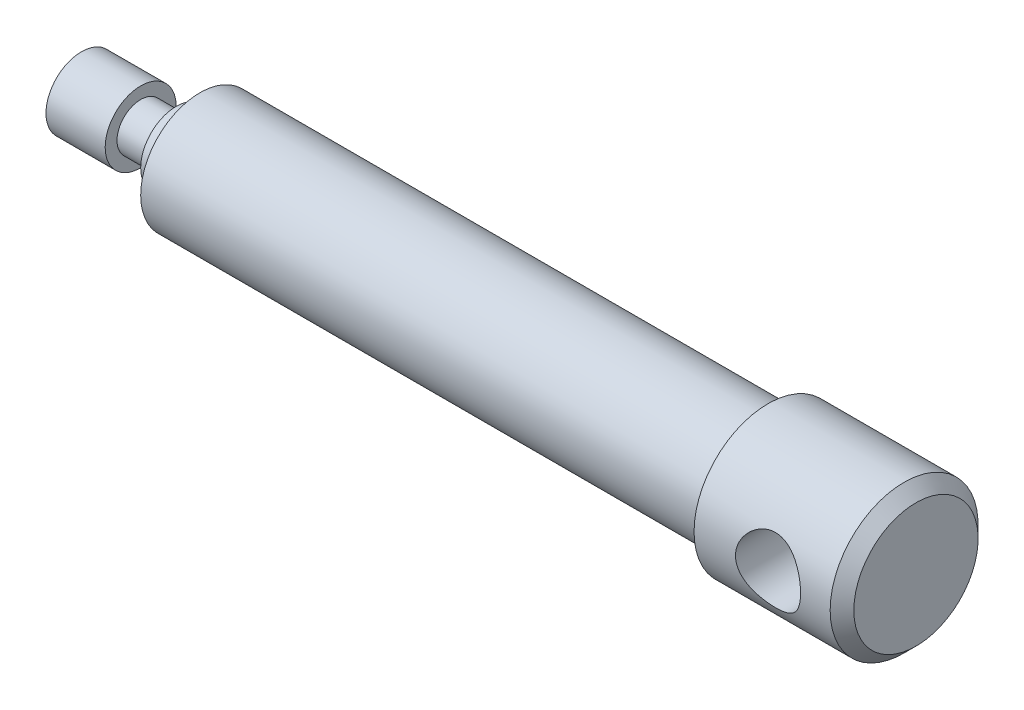
from build123d import *

# Parameters (mm, degrees)
SKETCH2_R               = 5.5
CUT_EXTRUDE1_DEPTH      = 13.5
CUT_EXTRUDE1_DEPTH_BACK = 13.5


with BuildPart() as part:
    # Sketch1 → Revolve1 (revolve)
    with BuildSketch(Plane.XY):
        Polygon((3.464101615, 6), (0, 0), (144.464101615, 0), (144.464101615, 10.5), (142.464101615, 12.5), (119.464101615, 12.5), (119.464101615, 10), (23.464101615, 10), (23.464101615, 6), (19.464101615, 6), (19.464101615, 4), (13.464101615, 4), (13.464101615, 6), align=None)
    revolve(axis=Axis((0, 0, 0), (1, 0, 0)))

    # Sketch2 → Cut-Extrude1 (cut, two sides)
    with BuildSketch(Plane.XY) as cut_extrude1_sk:
        with Locations((131.964101615, 0)):
            Circle(SKETCH2_R)
    extrude(amount=CUT_EXTRUDE1_DEPTH, mode=Mode.SUBTRACT)
    extrude(cut_extrude1_sk.sketch, amount=-CUT_EXTRUDE1_DEPTH_BACK, mode=Mode.SUBTRACT)


solid = part.part
